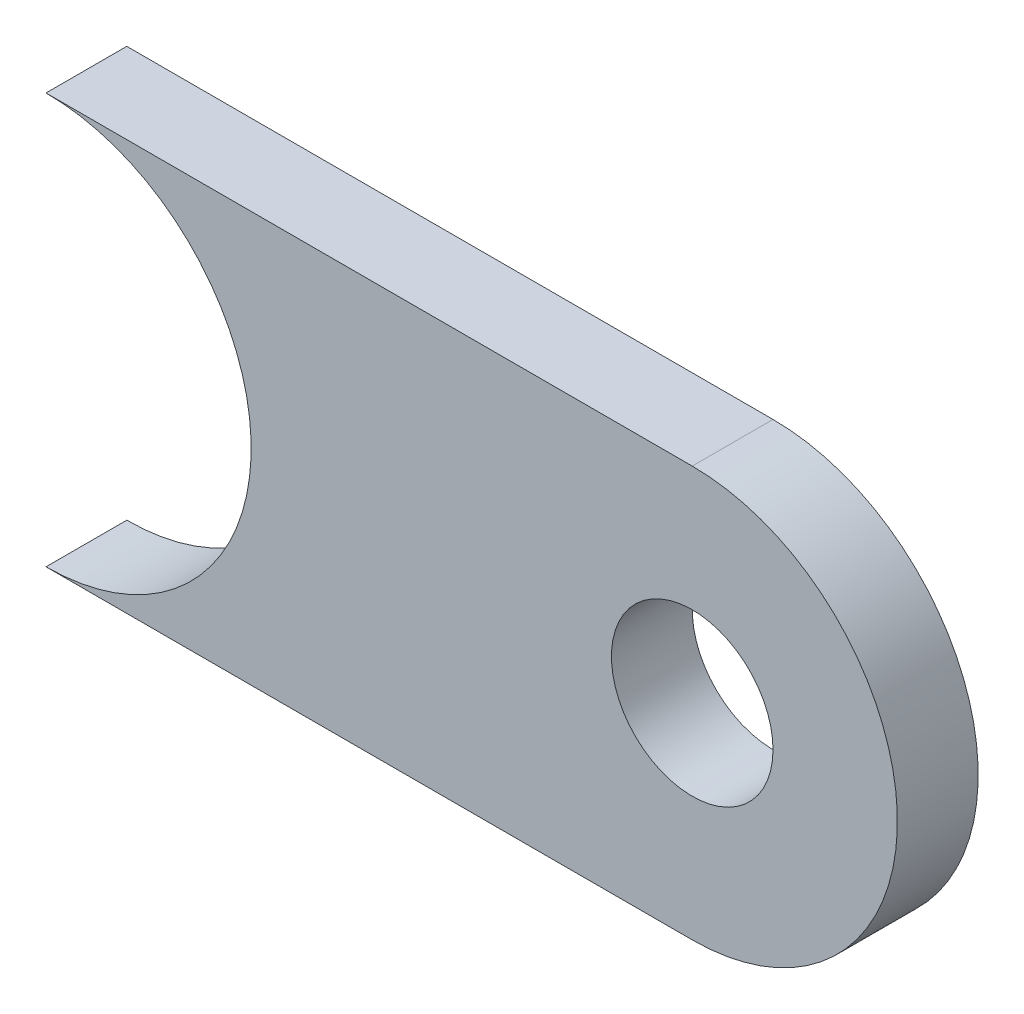
from build123d import *

# Parameters (mm, degrees)
SKETCH2_R           = 5
BOSS_EXTRUDE2_DEPTH = 5


with BuildPart() as part:
    # Sketch2 → Boss-Extrude2 (new body)
    with BuildSketch(Plane.XY):
        with BuildLine():
            Line((0, 12.7), (40, 12.7))
            ThreePointArc((40, 12.7), (52.7, 0), (40, -12.7))
            Line((40, -12.7), (0, -12.7))
            ThreePointArc((0, -12.7), (12.7, 0), (0, 12.7))
        make_face()
        with Locations((40, 0)):
            Circle(SKETCH2_R, mode=Mode.SUBTRACT)
    extrude(amount=BOSS_EXTRUDE2_DEPTH)


solid = part.part
